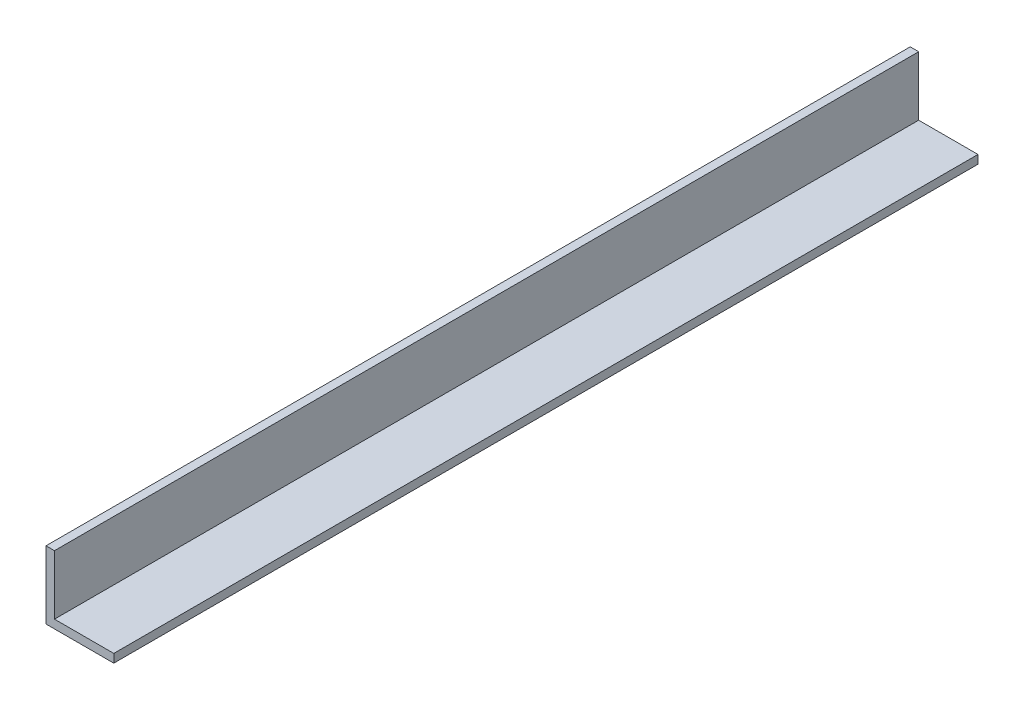
from build123d import *

# Parameters (mm, degrees)
BOSS_EXTRUDE1_DEPTH = 323.85


with BuildPart() as part:
    # Sketch1 → Boss-Extrude1 (new body)
    with BuildSketch(Plane.XY):
        Polygon((0, 0), (25.4, 0), (25.4, 3.175), (3.175, 3.175), (3.175, 25.4), (0, 25.4), align=None)
    extrude(amount=BOSS_EXTRUDE1_DEPTH)


solid = part.part
